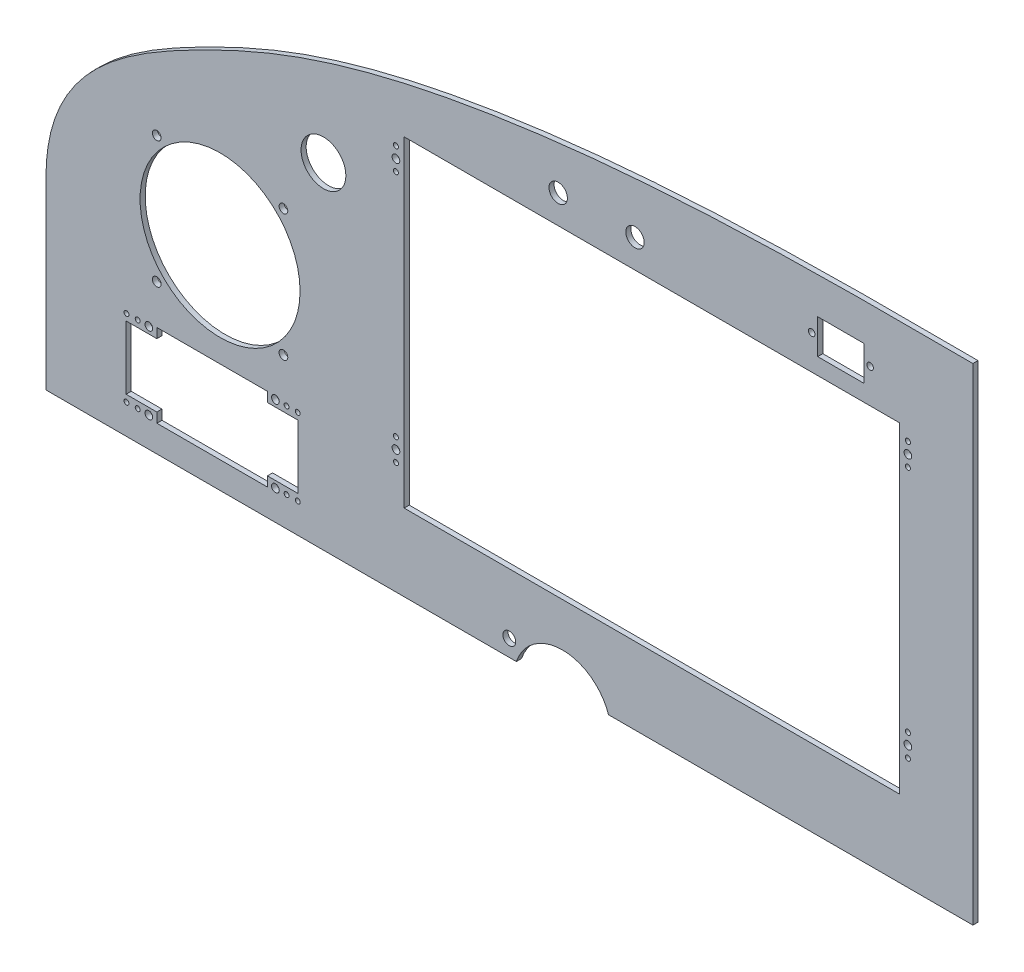
from build123d import *

# Parameters (mm, degrees)
SKETCH1_R           = 3.175
BOSS_EXTRUDE1_DEPTH = 2.54
CUTOUTS_R           = 11.1125
CUTOUTS_R_2         = 4.572
CUTOUTS_W           = 22.987
CUTOUTS_H           = 17.145
CUTOUTS_R_3         = 1.63195
CUTOUTS_W_2         = 245.872
CUTOUTS_H_2         = 159.512
CUTOUTS_R_4         = 1.905
CUTOUTS_R_5         = 1.2446
CUTOUTS_R_6         = 1.2192
CUTOUTS_R_7         = 2.159
CUTOUTS_R_8         = 39.6875
CUT_EXTRUDE2_DEPTH  = 2.54


with BuildPart() as part:
    # Sketch1 → Boss-Extrude1 (new body)
    with BuildSketch(Plane.XY):
        with BuildLine():
            Line((12.466633151, -16.004721173), (-220.895866849, -16.004721173))
            Line((-220.895866849, -16.004721173), (-220.895866849, 75.745957455))
            add(Edge.make_bspline(
                [(238.947265279, 225.295278827), (159.185673744, 225.799300987), (43.873806561, 224.990313445), (-86.64121676, 195.723193048), (-170.078039566, 157.179815606), (-220.832811132, 123.612518821), (-220.895866849, 75.745957455)],
                knots=[0, 0, 0, 0, 0.46349441, 0.667883071, 0.767851209, 1, 1, 1, 1], degree=3))
            Line((238.947265279, 225.295278827), (238.947265279, -16.004721173))
            Line((238.947265279, -16.004721173), (58.186633151, -16.004721173))
            ThreePointArc((58.186633151, -16.004721173), (35.326633151, 0.432794328), (12.466633151, -16.004721173))
        make_face()
        with Locations((8.951187051, -7.800096672)):
            Circle(SKETCH1_R, mode=Mode.SUBTRACT)
    extrude(amount=BOSS_EXTRUDE1_DEPTH)

    # Cutouts → Cut-Extrude2 (cut)
    with BuildSketch(Plane.XY.offset(2.54)):
        with Locations((-83.250919967, 150.449868461)):
            Circle(CUTOUTS_R)
        with Locations((33.209986811, 195.753851713)):
            Circle(CUTOUTS_R_2)
        with Locations((71.309986811, 195.753851713)):
            Circle(CUTOUTS_R_2)
        with Locations((173.460984528, 198.334802895)):
            Rectangle(CUTOUTS_W, CUTOUTS_H)
        with Locations((158.957584528, 198.612997235)):
            Circle(CUTOUTS_R_3)
        with Locations((187.964384528, 198.612997235)):
            Circle(CUTOUTS_R_3)
        with Locations((79.716556409, 101.851278827)):
            Rectangle(CUTOUTS_W_2, CUTOUTS_H_2)
        with Locations((-47.283443591, 170.177278827)):
            Circle(CUTOUTS_R_4)
        with Locations((-47.283443591, 164.627278827)):
            Circle(CUTOUTS_R_5)
        with Locations((-47.283443591, 45.209278827)):
            Circle(CUTOUTS_R_4)
        with Locations((-47.283443591, 39.659278827)):
            Circle(CUTOUTS_R_5)
        with Locations((206.716556409, 45.209278827)):
            Circle(CUTOUTS_R_4)
        with Locations((206.716556409, 39.659278827)):
            Circle(CUTOUTS_R_5)
        with Locations((206.716556409, 170.177278827)):
            Circle(CUTOUTS_R_4)
        with Locations((-47.283443591, 175.727278827)):
            Circle(CUTOUTS_R_5)
        with Locations((-47.283443591, 50.759278827)):
            Circle(CUTOUTS_R_5)
        with Locations((206.716556409, 175.727278827)):
            Circle(CUTOUTS_R_5)
        with Locations((206.716556409, 164.627278827)):
            Circle(CUTOUTS_R_5)
        with Locations((206.716556409, 50.759278827)):
            Circle(CUTOUTS_R_5)
        Polygon((-95.799367816, 2.039302847), (-95.799367816, 33.535302847), (-111.039367816, 33.535302847), (-111.039367816, 38.361302847), (-165.903367816, 38.361302847), (-165.903367816, 33.535302847), (-181.143367816, 33.535302847), (-181.143367816, 2.039302847), (-165.903367816, 2.039302847), (-165.903367816, -2.786697153), (-111.039367816, -2.786697153), (-111.039367816, 2.039302847), align=None)
        with Locations((-169.865767816, 36.837302847)):
            Circle(CUTOUTS_R_4)
        with Locations((-107.076967816, -1.262697153)):
            Circle(CUTOUTS_R_4)
        with Locations((-107.076967816, 36.837302847)):
            Circle(CUTOUTS_R_4)
        with Locations((-175.402967816, 36.837302847)):
            Circle(CUTOUTS_R_6)
        with Locations((-180.965567816, 36.837302847)):
            Circle(CUTOUTS_R_6)
        with Locations((-169.865767816, -1.262697153)):
            Circle(CUTOUTS_R_4)
        with Locations((-175.402967816, -1.262697153)):
            Circle(CUTOUTS_R_6)
        with Locations((-180.965567816, -1.262697153)):
            Circle(CUTOUTS_R_6)
        with Locations((-101.539767816, -1.262697153)):
            Circle(CUTOUTS_R_6)
        with Locations((-95.977167816, -1.262697153)):
            Circle(CUTOUTS_R_6)
        with Locations((-101.539767816, 36.837302847)):
            Circle(CUTOUTS_R_6)
        with Locations((-95.977167816, 36.837302847)):
            Circle(CUTOUTS_R_6)
        with Locations((-103.103366849, 57.972778827)):
            Circle(CUTOUTS_R_7)
        with Locations((-134.535866849, 89.405278827)):
            Circle(CUTOUTS_R_8)
        with Locations((-165.968366849, 57.972778827)):
            Circle(CUTOUTS_R_7)
        with Locations((-103.103366849, 120.837778827)):
            Circle(CUTOUTS_R_7)
        with Locations((-165.968366849, 120.837778827)):
            Circle(CUTOUTS_R_7)
    extrude(amount=-CUT_EXTRUDE2_DEPTH, mode=Mode.SUBTRACT)


solid = part.part
